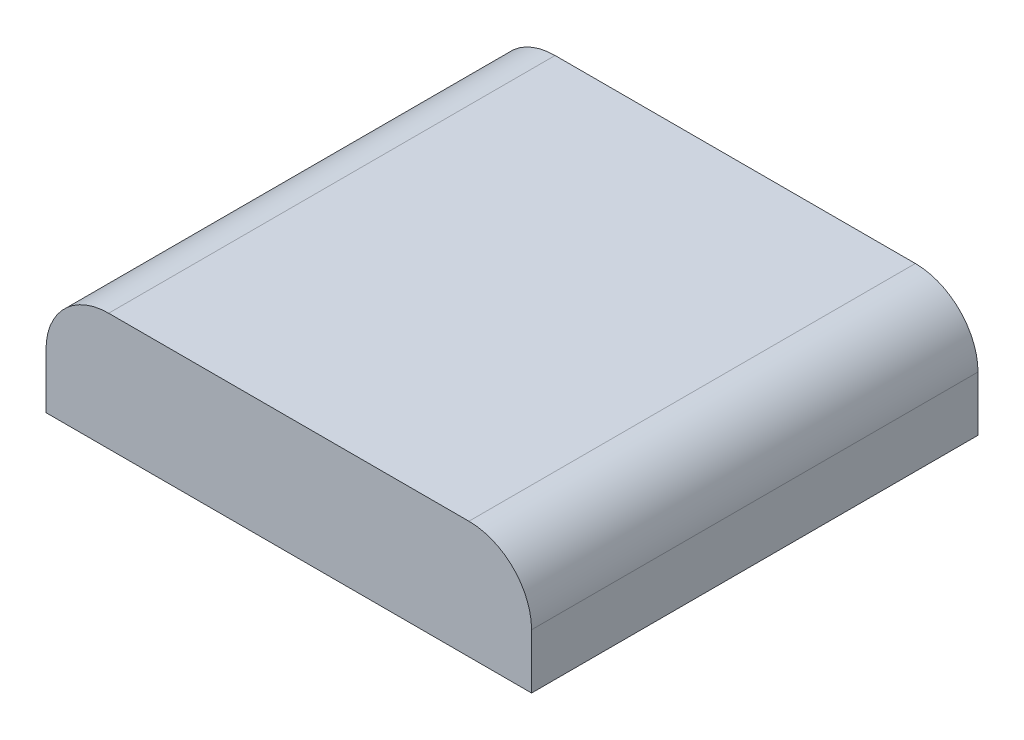
from build123d import *

# Parameters (mm, degrees)
SKETCH1_W           = 62
SKETCH1_H           = 57
BOSS_EXTRUDE1_DEPTH = 15
FILLET1_R           = 8


with BuildPart() as part:
    # Sketch1 → Boss-Extrude1 (new body)
    with BuildSketch(Plane(origin=(0, 0, 0), x_dir=(1, 0, 0), z_dir=(0, 1, 0))):
        with Locations((31, 28.5)):
            Rectangle(SKETCH1_W, SKETCH1_H)
    extrude(amount=BOSS_EXTRUDE1_DEPTH)

    # Fillet1
    fillet1_edges = [part.edges().sort_by_distance(p)[0] for p in [
        (62, 15, -28.5),
        (0, 15, -28.5),
    ]]
    fillet(fillet1_edges, radius=FILLET1_R)


solid = part.part
